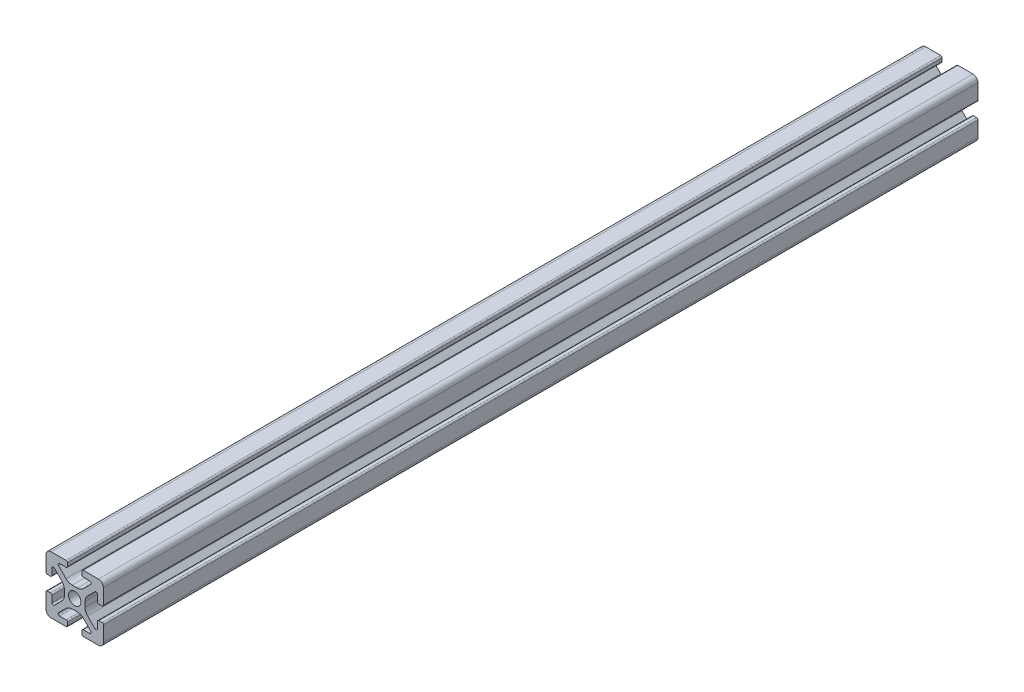
from build123d import *

# Parameters (mm, degrees)
BOSS_EXTRUDE1_DEPTH = 152.4


with BuildPart() as part:
    # Sketch4 → Boss-Extrude1 (new body, symmetric)
    with BuildSketch(Plane.XY):
        with BuildLine():
            Line((3, -10), (8.25, -10))
            ThreePointArc((8.25, -10), (9.487436867, -9.487436867), (10, -8.25))
            Line((10, -8.25), (10, -3))
            ThreePointArc((10, -3), (9.853553391, -2.646446609), (9.5, -2.5))
            Line((9.5, -2.5), (8.424621202, -2.5))
            ThreePointArc((8.424621202, -2.5), (8.071067812, -2.646446609), (7.924621202, -3))
            Line((7.924621202, -3), (7.924621202, -5.25))
            ThreePointArc((7.924621202, -5.25), (7.615962919, -5.711939766), (7.071067812, -5.603553391))
            Line((7.071067812, -5.603553391), (4.478679656, -3.011165235))
            ThreePointArc((4.478679656, -3.011165235), (3.828361402, -2.037895189), (3.6, -0.889844892))
            Line((3.6, -0.889844892), (3.6, 0))
            Line((3.6, 0), (2.15, 0))
            ThreePointArc((2.15, 0), (1.52027958, -1.52027958), (0, -2.15))
            Line((0, -2.15), (0, -3.6))
            Line((0, -3.6), (0.889844892, -3.6))
            ThreePointArc((0.889844892, -3.6), (2.037895189, -3.828361402), (3.011165235, -4.478679656))
            Line((3.011165235, -4.478679656), (5.603553391, -7.071067812))
            ThreePointArc((5.603553391, -7.071067812), (5.711939766, -7.615962919), (5.25, -7.924621202))
            Line((5.25, -7.924621202), (3, -7.924621202))
            ThreePointArc((3, -7.924621202), (2.646446609, -8.071067812), (2.5, -8.424621202))
            Line((2.5, -8.424621202), (2.5, -9.5))
            ThreePointArc((2.5, -9.5), (2.646446609, -9.853553391), (3, -10))
        make_face()
    extrude(amount=BOSS_EXTRUDE1_DEPTH, both=True)

    # Mirror1: part across plane


with BuildPart() as part_1:
    add(part.part)
    add(part.part.mirror(Plane(origin=(0, 0, 0), x_dir=(0, 0, 1), z_dir=(1, 0, 0))))

    # Mirror2: part across plane


with BuildPart() as part_2:
    add(part_1.part)
    add(part_1.part.mirror(Plane.ZX))


solid = part_2.part
